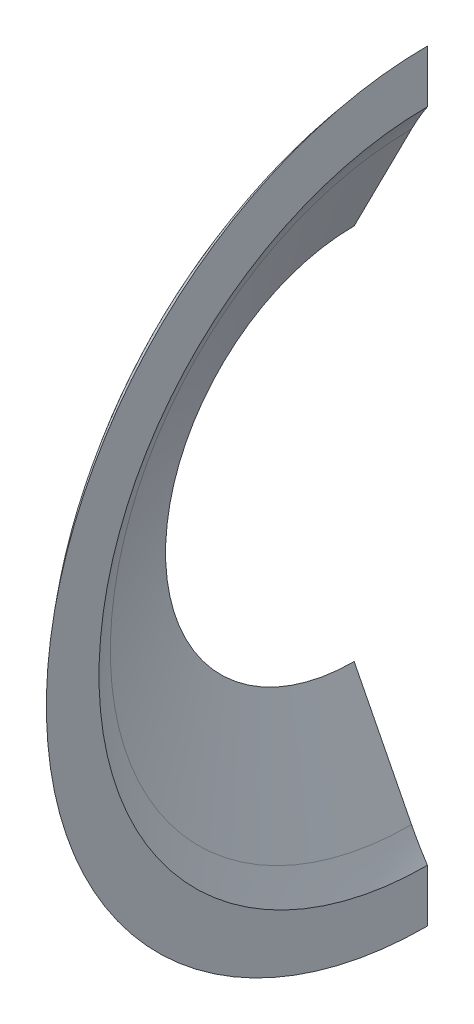
from build123d import *

# Parameters (mm, degrees)
SCALE1_SCALE       = 649.76746201
SHELL2_T           = 5.588
SKETCH3_R          = 101.6
SKETCH3_R_2        = 66.04
CUT_EXTRUDE2_DEPTH = 535.742534837
CUT_EXTRUDE3_START = -41.91
SKETCH4_R          = 92.04718224
CUT_EXTRUDE3_DEPTH = 41.91
CUT_EXTRUDE4_START = -12.7
SKETCH5_R          = 73.005644817
CUT_EXTRUDE4_DEPTH = 50.8
SKETCH6_W          = 424.059423161
SKETCH6_H          = 690.342462677
CUT_EXTRUDE5_DEPTH = 250.634607617


with BuildPart() as part:
    # Sketch1 → Revolve2 (revolve)
    with BuildSketch(Plane.XY, mode=Mode.PRIVATE) as revolve2_sk:
        with BuildLine():
            Line((0.30325, 0.129), (-0.275595218, 0.129))
            ThreePointArc((-0.275595218, 0.129), (-0.3184401, 0.116916493), (-0.348657753, 0.084227221))
            Line((-0.348657753, 0.084227221), (-0.372858421, 0.036730735))
            ThreePointArc((-0.372858421, 0.036730735), (-0.374701425, 0.034736985), (-0.377314576, 0.034))
            Line((-0.377314576, 0.034), (-0.40125, 0.034))
            Line((-0.40125, 0.034), (-0.40125, 0))
            Line((-0.40125, 0), (0.40125, 0))
            Line((0.40125, 0), (0.40125, 0.000587576))
            ThreePointArc((0.40125, 0.000587576), (0.399958659, 0.015347671), (0.396123873, 0.029659288))
            Line((0.396123873, 0.029659288), (0.379365102, 0.075703632))
            ThreePointArc((0.379365102, 0.075703632), (0.349709691, 0.114351316), (0.30325, 0.129))
        make_face()
    revolve(revolve2_sk.sketch.rotate(Axis((-0.40125, 0, 0), (1, 0, 0)), 90), axis=Axis((-0.40125, 0, 0), (1, 0, 0)))


with BuildPart() as part_1:
    # Scale1: scaled about (0, 0, 0)
    add(part.part.scale(SCALE1_SCALE))

    # Shell2 (no face opened: a closed hollow body)
    add(offset(amount=-SHELL2_T, mode=Mode.PRIVATE), mode=Mode.SUBTRACT)

    # Sketch3 → Cut-Extrude2 (cut, through all)
    with BuildSketch(Plane.ZY.offset(260.719194132)):
        Circle(SKETCH3_R)
        with Locations(Location((0, 0, 0), (0, 0, 180))):
            Circle(SKETCH3_R_2, mode=Mode.SUBTRACT)
    extrude(amount=-CUT_EXTRUDE2_DEPTH, mode=Mode.SUBTRACT)


with BuildPart() as body_2:
    # of the pieces the cut leaves, the one that is kept (cut_extrude2_keep)
    add(part_1.part.solids().sort_by_distance((-218.803671245, 0, 66.04))[0])

    # Sketch4 → Cut-Extrude3 (cut)
    with BuildSketch(Plane.ZY.offset(260.719194132).offset(CUT_EXTRUDE3_START)):
        Circle(SKETCH4_R)
    extrude(amount=-CUT_EXTRUDE3_DEPTH, mode=Mode.SUBTRACT)

    # Sketch5 → Cut-Extrude4 (cut)
    with BuildSketch(Plane(origin=(-218.809194132, 0, 0), x_dir=(0, 0, -1), z_dir=(1, 0, 0)).offset(CUT_EXTRUDE4_START)):
        Circle(SKETCH5_R)
    extrude(amount=-CUT_EXTRUDE4_DEPTH, mode=Mode.SUBTRACT)

    # Sketch6 → Cut-Extrude5 (cut, through all)
    with BuildSketch(Plane.XY):
        with Locations((-333.697276698, 135.370996171)):
            Rectangle(SKETCH6_W, SKETCH6_H)
    extrude(amount=-CUT_EXTRUDE5_DEPTH, mode=Mode.SUBTRACT)


solid = body_2.part
